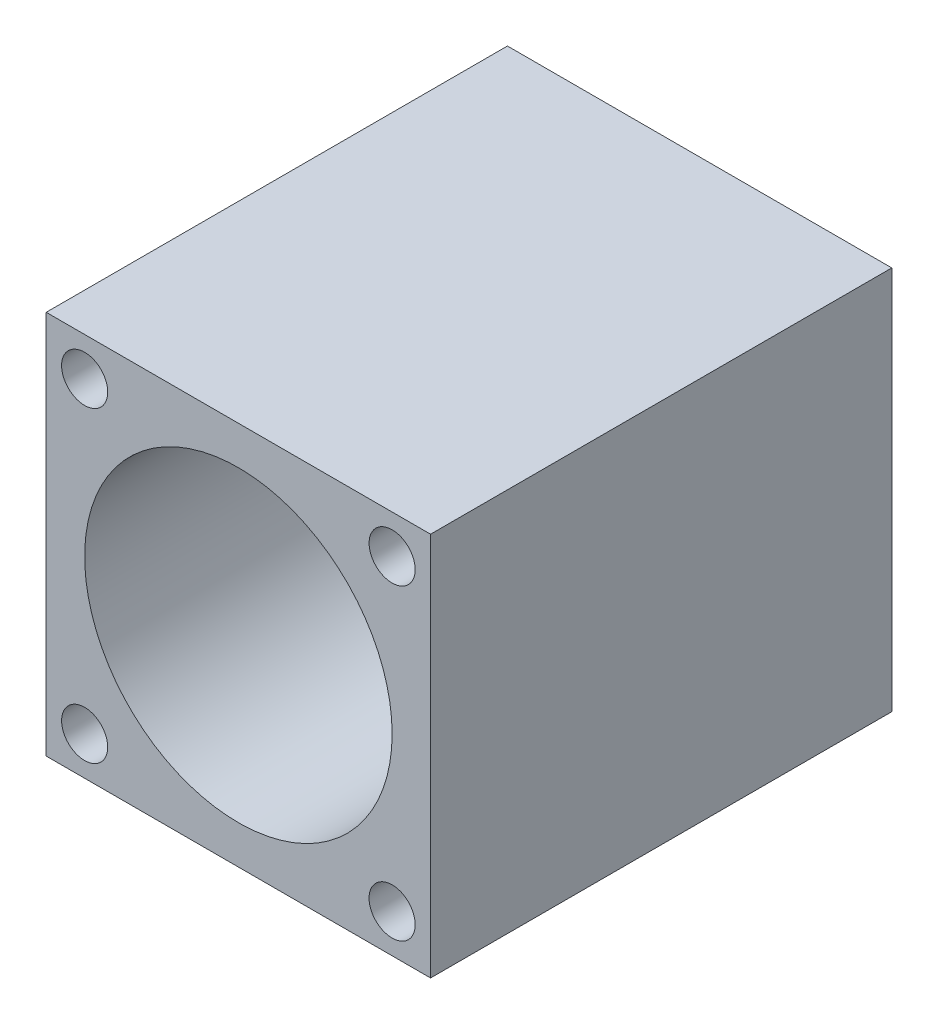
from build123d import *

# Parameters (mm, degrees)
ESQUISSE1_W      = 25
ESQUISSE1_H      = 25
ESQUISSE1_R      = 1.5
ESQUISSE1_R_2    = 3
EXTRUSION3_DEPTH = 30
ESQUISSE8_R      = 10
EXTRUSION4_DEPTH = 28


with BuildPart() as part:
    # Esquisse1 → Extrusion3 (new body)
    with BuildSketch(Plane.XY):
        Rectangle(ESQUISSE1_W, ESQUISSE1_H)
        with Locations((10, 10)):
            Circle(ESQUISSE1_R, mode=Mode.SUBTRACT)
        Circle(ESQUISSE1_R_2, mode=Mode.SUBTRACT)
        with Locations((-10, 10)):
            Circle(ESQUISSE1_R, mode=Mode.SUBTRACT)
        with Locations((10, -10)):
            Circle(ESQUISSE1_R, mode=Mode.SUBTRACT)
        with Locations((-10, -10)):
            Circle(ESQUISSE1_R, mode=Mode.SUBTRACT)
    extrude(amount=EXTRUSION3_DEPTH)

    # Esquisse8 → Extrusion4 (cut)
    with BuildSketch(Plane.XY.offset(30)):
        Circle(ESQUISSE8_R)
    extrude(amount=-EXTRUSION4_DEPTH, mode=Mode.SUBTRACT)


solid = part.part
